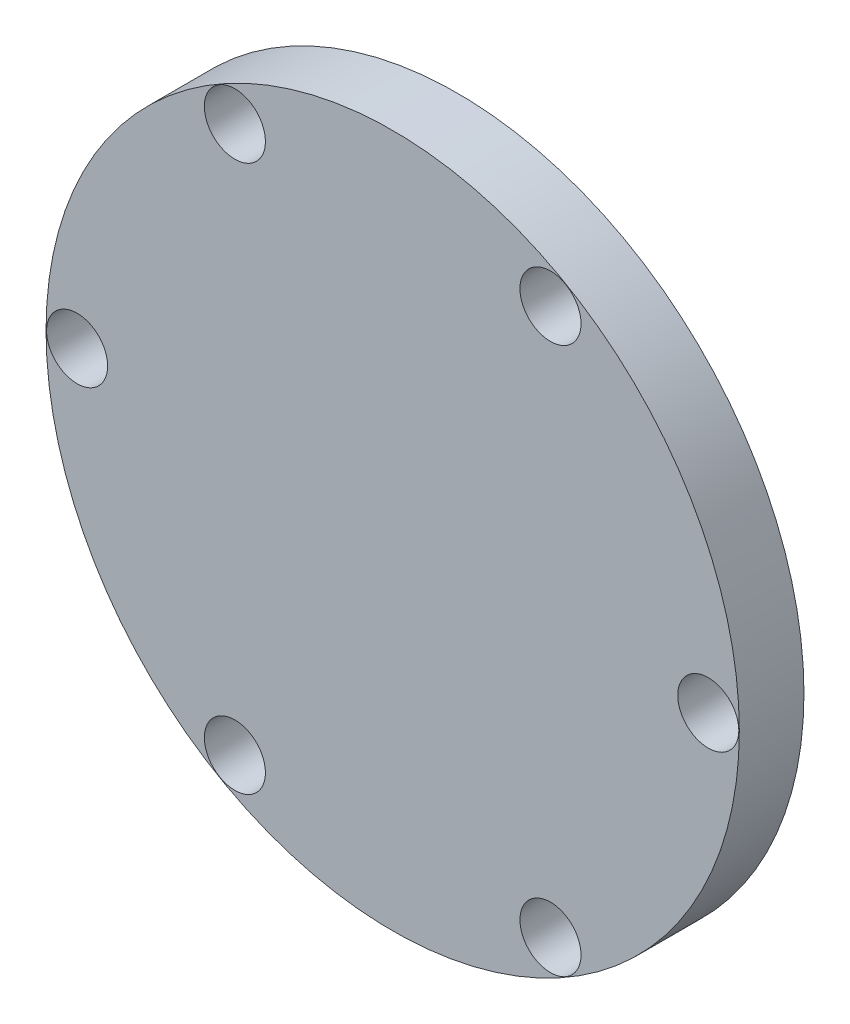
from build123d import *

# Parameters (mm, degrees)
SKETCH1_R           = 17.025679244
SKETCH1_R_2         = 1.5
BOSS_EXTRUDE1_DEPTH = 3.175


with BuildPart() as part:
    # Sketch1 → Boss-Extrude1 (new body)
    with BuildSketch(Plane.XY):
        Circle(SKETCH1_R)
        with Locations((-15.5, 0)):
            Circle(SKETCH1_R_2, mode=Mode.SUBTRACT)
        with Locations((-7.75, 13.423393759)):
            Circle(SKETCH1_R_2, mode=Mode.SUBTRACT)
        with Locations((7.75, 13.423393759)):
            Circle(SKETCH1_R_2, mode=Mode.SUBTRACT)
        with Locations((15.5, 0)):
            Circle(SKETCH1_R_2, mode=Mode.SUBTRACT)
        with Locations((7.75, -13.423393759)):
            Circle(SKETCH1_R_2, mode=Mode.SUBTRACT)
        with Locations((-7.75, -13.423393759)):
            Circle(SKETCH1_R_2, mode=Mode.SUBTRACT)
    extrude(amount=BOSS_EXTRUDE1_DEPTH)


solid = part.part
